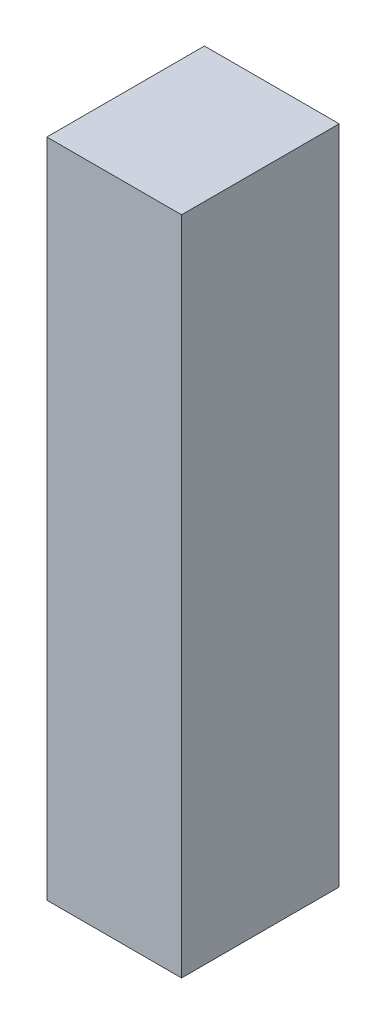
from build123d import *

# Parameters (mm, degrees)
SKETCH1_W           = 5.3
SKETCH1_H           = 6.2
BOSS_EXTRUDE1_DEPTH = 26
CUT_EXTRUDE1_DEPTH  = 1


with BuildPart() as part:
    # Sketch1 → Boss-Extrude1 (new body)
    with BuildSketch(Plane(origin=(0, 0, 0), x_dir=(1, 0, 0), z_dir=(0, 1, 0))):
        with Locations((2.65, 3.1)):
            Rectangle(SKETCH1_W, SKETCH1_H)
    extrude(amount=BOSS_EXTRUDE1_DEPTH)

    # Sketch2 → Cut-Extrude1 (cut)
    with BuildSketch(Plane(origin=(0, 0, -6.2), x_dir=(-1, 0, 0), z_dir=(0, 0, -1))):
        with BuildLine():
            Line((-4.485897436, -0.081410256), (-4.713591747, 0.076958133))
            Line((-4.713591747, 0.076958133), (-3.830799279, 1.367437901))
            add(Edge.make_bspline(
                [(-3.830799279, 1.367437901), (-3.887124446, 1.360549907), (-3.998031841, 1.346987065), (-4.109734783, 1.344495457), (-4.164708534, 1.343269231)],
                knots=[0, 0, 0, 0, 0.000170115, 0.000334967, 0.000334967, 0.000334967, 0.000334967], degree=3))
            add(Edge.make_bspline(
                [(-4.164708534, 1.343269231), (-4.19803882, 1.344122922), (-4.263463257, 1.345798642), (-4.359649113, 1.359080854), (-4.452073872, 1.379537041), (-4.540492502, 1.410061269), (-4.625237338, 1.447996358), (-4.706123378, 1.495038078), (-4.783041736, 1.5503795), (-4.855166315, 1.613727999), (-4.920763393, 1.683285947), (-4.979204527, 1.756905709), (-5.027773982, 1.835442482), (-5.068120599, 1.917294181), (-5.098718939, 2.003637264), (-5.12100067, 2.093489219), (-5.134718806, 2.18747978), (-5.136350842, 2.251456149), (-5.137179487, 2.283939303)],
                knots=[0, 0, 0, 0, 9.9954e-05, 0.000196201, 0.000290782, 0.000383503, 0.000476303, 0.000568919, 0.000663705, 0.000760153, 0.000856434, 0.000950205, 0.001041624, 0.001132931, 0.001223461, 0.001315861, 0.001410305, 0.001507717, 0.001507717, 0.001507717, 0.001507717], degree=3))
            add(Edge.make_bspline(
                [(-5.137179487, 2.283939303), (-5.135606107, 2.328360866), (-5.132517881, 2.415551384), (-5.107663512, 2.542944875), (-5.066787347, 2.663401239), (-5.009793034, 2.776603772), (-4.938006536, 2.880924057), (-4.851729458, 2.974911867), (-4.751486576, 3.057230413), (-4.639561459, 3.127991255), (-4.518591219, 3.184900859), (-4.391891793, 3.22684651), (-4.260433984, 3.25151966), (-4.171381883, 3.254772549), (-4.126547476, 3.256410256)],
                knots=[0, 0, 0, 0, 0.000133185, 0.000261414, 0.000387724, 0.00051373, 0.000640399, 0.00076644, 0.000895188, 0.001028407, 0.001162697, 0.001295241, 0.001427846, 0.0015623, 0.0015623, 0.0015623, 0.0015623], degree=3))
            add(Edge.make_bspline(
                [(-4.126547476, 3.256410256), (-4.082561552, 3.254750037), (-3.995649514, 3.2514696), (-3.867843058, 3.227444857), (-3.745432278, 3.186953018), (-3.629095754, 3.130996306), (-3.521382145, 3.060855197), (-3.42452123, 2.977276022), (-3.34072342, 2.880206723), (-3.270126042, 2.771995021), (-3.213456791, 2.655729259), (-3.172569792, 2.53436813), (-3.147400534, 2.408784432), (-3.144228865, 2.323699445), (-3.142628205, 2.280759215)],
                knots=[0, 0, 0, 0, 0.000131915, 0.000260652, 0.000388569, 0.000517718, 0.000646848, 0.000773094, 0.000900237, 0.001030248, 0.001159674, 0.001287189, 0.001413545, 0.001542287, 0.001542287, 0.001542287, 0.001542287], degree=3))
            add(Edge.make_bspline(
                [(-3.142628205, 2.280759215), (-3.14369719, 2.247427369), (-3.14586536, 2.179822057), (-3.161047581, 2.07710596), (-3.186828749, 1.972375202), (-3.216085647, 1.883727754), (-3.244326971, 1.810513661), (-3.270907283, 1.75268187), (-3.300400451, 1.691811439), (-3.334798188, 1.628540639), (-3.371775414, 1.562062911), (-3.413557758, 1.493045019), (-3.459192098, 1.421394347), (-3.491694773, 1.373091631), (-3.508338341, 1.348357372)],
                knots=[0, 0, 0, 0, 9.9984e-05, 0.000202793, 0.000310776, 0.000423207, 0.000482616, 0.000546097, 0.000614079, 0.0006855, 0.000762103, 0.000842274, 0.000927493, 0.001016928, 0.001016928, 0.001016928, 0.001016928], degree=3))
            Line((-3.508338341, 1.348357372), (-4.485897436, -0.081410256))
        make_face()
        with BuildLine():
            add(Edge.make_bspline(
                [(-4.111919071, 1.668910256), (-4.086669643, 1.669600033), (-4.037517593, 1.670942794), (-3.965511043, 1.679115463), (-3.897544087, 1.693606151), (-3.833435168, 1.714397604), (-3.772541478, 1.739486153), (-3.715830238, 1.771428455), (-3.663253984, 1.809543545), (-3.61446065, 1.852369774), (-3.571131879, 1.899949946), (-3.532539272, 1.949749464), (-3.499736472, 2.001986932), (-3.473825499, 2.057316534), (-3.452521634, 2.11439143), (-3.43780958, 2.174130738), (-3.429659507, 2.236223216), (-3.428270149, 2.278404141), (-3.427564103, 2.299839744)],
                knots=[0, 0, 0, 0, 7.5753e-05, 0.000147465, 0.000217073, 0.000283852, 0.000349411, 0.000414338, 0.000478589, 0.000543925, 0.000608743, 0.000671332, 0.000732749, 0.000793345, 0.000854313, 0.000915245, 0.00097749, 0.001041807, 0.001041807, 0.001041807, 0.001041807], degree=3))
            add(Edge.make_bspline(
                [(-3.427564103, 2.299839744), (-3.428171588, 2.321284297), (-3.429368713, 2.36354342), (-3.438972906, 2.425727827), (-3.455868645, 2.485320999), (-3.478538584, 2.542649189), (-3.508401943, 2.597241384), (-3.544237248, 2.649782982), (-3.586811684, 2.69994084), (-3.635799726, 2.746535311), (-3.688626785, 2.78948662), (-3.744924525, 2.82739256), (-3.804228913, 2.859161788), (-3.866178143, 2.885377282), (-3.930901288, 2.905834965), (-3.998360049, 2.920546431), (-4.06889531, 2.928685094), (-4.116775476, 2.93006567), (-4.141175881, 2.930769231)],
                knots=[0, 0, 0, 0, 6.4316e-05, 0.000126743, 0.000188161, 0.000249812, 0.000311283, 0.000374438, 0.00044032, 0.000508243, 0.00057698, 0.000644365, 0.000711521, 0.0007785, 0.000845884, 0.000914871, 0.00098532, 0.001058531, 0.001058531, 0.001058531, 0.001058531], degree=3))
            add(Edge.make_bspline(
                [(-4.141175881, 2.930769231), (-4.165364078, 2.930064533), (-4.21282112, 2.928681923), (-4.282729321, 2.920561901), (-4.349731952, 2.905736026), (-4.414267565, 2.885386758), (-4.476214954, 2.859159833), (-4.535516545, 2.827390896), (-4.591827453, 2.789495345), (-4.644603864, 2.746501516), (-4.693678408, 2.700157723), (-4.735520852, 2.649563255), (-4.771438168, 2.597268715), (-4.801260492, 2.542641926), (-4.823941347, 2.485322938), (-4.840834163, 2.425727302), (-4.850439142, 2.363543557), (-4.851636159, 2.321284343), (-4.85224359, 2.299839744)],
                knots=[0, 0, 0, 0, 7.2576e-05, 0.000142393, 0.000210758, 0.000278143, 0.000345121, 0.000412278, 0.000479663, 0.0005484, 0.000616323, 0.000681795, 0.00074495, 0.000806421, 0.000868072, 0.00092949, 0.000991917, 0.001056233, 0.001056233, 0.001056233, 0.001056233], degree=3))
            add(Edge.make_bspline(
                [(-4.85224359, 2.299839744), (-4.851693928, 2.278387449), (-4.850609895, 2.236079598), (-4.840152543, 2.17391637), (-4.822664389, 2.114327794), (-4.799242513, 2.056734467), (-4.768398214, 2.001696424), (-4.730548723, 1.949474603), (-4.686184406, 1.899477016), (-4.635898314, 1.852480474), (-4.580863625, 1.809343857), (-4.52208372, 1.771669868), (-4.46057051, 1.739854151), (-4.39610746, 1.714325895), (-4.329172291, 1.693813886), (-4.259163422, 1.67914217), (-4.186312378, 1.671021185), (-4.136954752, 1.66962065), (-4.111919071, 1.668910256)],
                knots=[0, 0, 0, 0, 6.4316e-05, 0.000126844, 0.000188436, 0.000250326, 0.000312966, 0.000377217, 0.000443451, 0.000513196, 0.000583426, 0.000652939, 0.000722346, 0.000790847, 0.000860662, 0.000932137, 0.001005113, 0.00108023, 0.00108023, 0.00108023, 0.00108023], degree=3))
        make_face(mode=Mode.SUBTRACT)
        Polygon((-2.532051282, 3.175), (-0.578205128, 3.175), (-2.247115385, -0.081410256), (-2.493254207, 0.054061498), (-1.06030649, 2.849358974), (-2.532051282, 2.849358974), align=None)
    extrude(amount=-CUT_EXTRUDE1_DEPTH, mode=Mode.SUBTRACT)


solid = part.part
